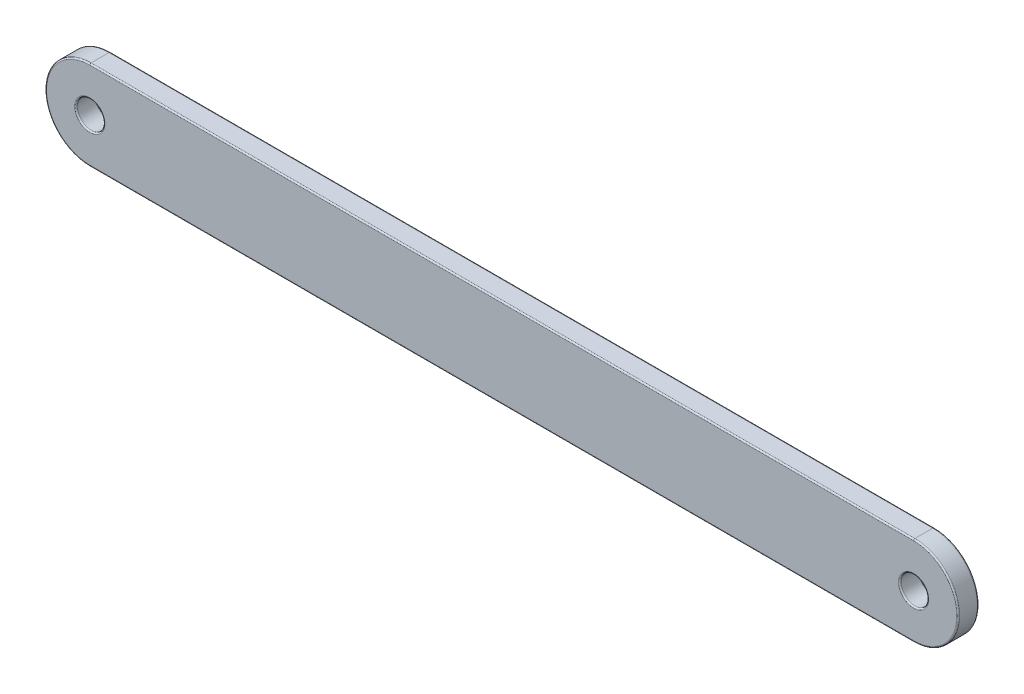
from build123d import *

# Parameters (mm, degrees)
SKETCH1_R           = 1
BOSS_EXTRUDE1_DEPTH = 1.5
FILLET1_R           = 0.1


with BuildPart() as part:
    # Sketch1 → Boss-Extrude1 (new body)
    with BuildSketch(Plane.XY):
        with BuildLine():
            Line((-30, 3.25), (30, 3.25))
            ThreePointArc((30, 3.25), (33.25, 0), (30, -3.25))
            Line((30, -3.25), (-30, -3.25))
            ThreePointArc((-30, -3.25), (-33.25, 0), (-30, 3.25))
        make_face()
        with Locations((-30, 0)):
            Circle(SKETCH1_R, mode=Mode.SUBTRACT)
        with Locations((30, 0)):
            Circle(SKETCH1_R, mode=Mode.SUBTRACT)
    extrude(amount=BOSS_EXTRUDE1_DEPTH)

    # Fillet1
    fillet1_edges = [part.edges().sort_by_distance(p)[0] for p in [
        (33.25, 0, 1.5),
        (-31, 0, 0),
        (-31, 0, 1.5),
        (0, 3.25, 1.5),
        (29, 0, 0),
        (29, 0, 1.5),
        (-33.25, 0, 1.5),
        (0, 3.25, 0),
        (33.25, 0, 0),
        (0, -3.25, 0),
        (-33.25, 0, 0),
        (0, -3.25, 1.5),
    ]]
    fillet(fillet1_edges, radius=FILLET1_R)


solid = part.part
